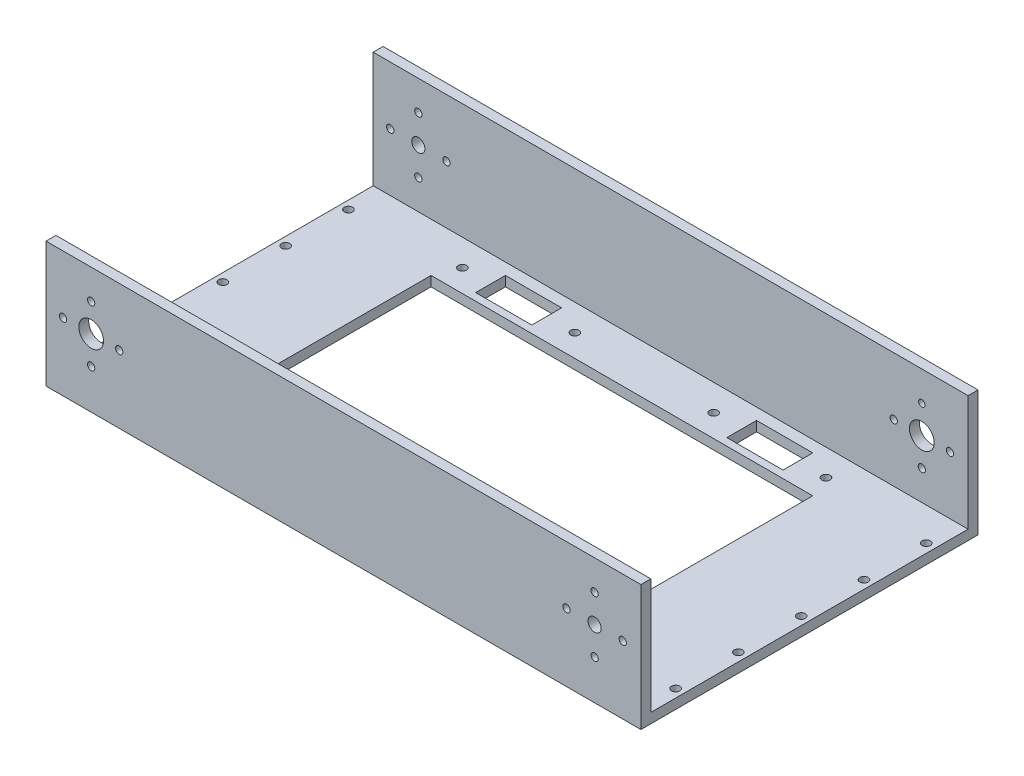
from build123d import *

# Parameters (mm, degrees)
SKETCH_1_W          = 180
SKETCH_1_H          = 35
EXTRUDE_1_DEPTH     = 3
SKETCH_2_R          = 3.75
SKETCH_2_R_2        = 2
CUT_EXTRUDE_1_DEPTH = 3
SKETCH_3_R          = 1.1
CUT_EXTRUDE_2_DEPTH = 3
SKETCH_4_W          = 180
SKETCH_4_H          = 102
EXTRUDE_2_DEPTH     = 3
SKETCH_5_W          = 180
SKETCH_5_H          = 3
EXTRUDE_3_DEPTH     = 35
SKETCH_6_R          = 3.75
SKETCH_6_R_2        = 2
SKETCH_6_R_3        = 1.1
SKETCH_6_R_4        = 0.981653735
CUT_EXTRUDE_3_DEPTH = 35
SKETCH_9_W          = 115.5
SKETCH_9_H          = 66.5
CUT_EXTRUDE_4_DEPTH = 10
SKETCH_10_R         = 1.25
CUT_EXTRUDE_5_DEPTH = 10
SKETCH_11_R         = 1.25
SKETCH_11_W         = 17
SKETCH_11_H         = 9
CUT_EXTRUDE_6_DEPTH = 10
SKETCH_12_R         = 1.25
CUT_EXTRUDE_7_DEPTH = 10


with BuildPart() as part:
    # 스케치1 → 보스-돌출1 (new body)
    with BuildSketch(Plane.XY):
        Rectangle(SKETCH_1_W, SKETCH_1_H)
    extrude(amount=EXTRUDE_1_DEPTH)

    # 스케치2 → 컷-돌출1 (cut)
    with BuildSketch(Plane.XY.offset(3)):
        with Locations((-76.33997629, 0)):
            Circle(SKETCH_2_R)
        with Locations((76, 0)):
            Circle(SKETCH_2_R_2)
    extrude(amount=-CUT_EXTRUDE_1_DEPTH, mode=Mode.SUBTRACT)

    # 스케치3 → 컷-돌출2 (cut)
    with BuildSketch(Plane.XY.offset(3)):
        with Locations((-76.33997629, 8.5)):
            Circle(SKETCH_3_R)
        with Locations((-76.33997629, -8.5)):
            Circle(SKETCH_3_R)
        with Locations((-84.83997629, 0)):
            Circle(SKETCH_3_R)
        with Locations((-67.83997629, 0)):
            Circle(SKETCH_3_R)
        with Locations((76, 8.5)):
            Circle(SKETCH_3_R)
        with Locations((76, -8.5)):
            Circle(SKETCH_3_R)
        with Locations((67.5, 0)):
            Circle(SKETCH_3_R)
        with Locations((84.5, 0)):
            Circle(SKETCH_3_R)
    extrude(amount=-CUT_EXTRUDE_2_DEPTH, mode=Mode.SUBTRACT)

    # 스케치4 → 보스-돌출2 (add)
    with BuildSketch(Plane.XZ.offset(17.5)):
        with Locations((0, -48)):
            Rectangle(SKETCH_4_W, SKETCH_4_H)
    extrude(amount=EXTRUDE_2_DEPTH)

    # 스케치5 → 보스-돌출3 (add)
    with BuildSketch(Plane(origin=(0, -17.5, 0), x_dir=(1, 0, 0), z_dir=(0, 1, 0))):
        with Locations((0, 97.5)):
            Rectangle(SKETCH_5_W, SKETCH_5_H)
    extrude(amount=EXTRUDE_3_DEPTH)

    # 스케치6 → 컷-돌출3 (cut)
    with BuildSketch(Plane(origin=(0, 0, -99), x_dir=(-1, 0, 0), z_dir=(0, 0, -1))):
        with Locations((-76, 0)):
            Circle(SKETCH_6_R)
        with Locations((76.33997629, 0)):
            Circle(SKETCH_6_R_2)
        with Locations((-76, -8.5)):
            Circle(SKETCH_6_R_3)
        with Locations((-67.5, 0)):
            Circle(SKETCH_6_R_3)
        with Locations((-76, 8.5)):
            Circle(SKETCH_6_R_4)
        with Locations((-84.5, 0)):
            Circle(SKETCH_6_R_3)
        with Locations((84.83997629, 0)):
            Circle(SKETCH_6_R_3)
        with Locations((76.33997629, 8.5)):
            Circle(SKETCH_6_R_3)
        with Locations((67.83997629, 0)):
            Circle(SKETCH_6_R_3)
        with Locations((76.33997629, -8.5)):
            Circle(SKETCH_6_R_3)
    extrude(amount=-CUT_EXTRUDE_3_DEPTH, mode=Mode.SUBTRACT)

    # 스케치9 → 컷-돌출4 (cut)
    with BuildSketch(Plane(origin=(0, -17.5, 0), x_dir=(1, 0, 0), z_dir=(0, 1, 0))):
        with Locations((0, 48)):
            Rectangle(SKETCH_9_W, SKETCH_9_H)
    extrude(amount=-CUT_EXTRUDE_4_DEPTH, mode=Mode.SUBTRACT)

    # 스케치10 → 컷-돌출5 (cut)
    with BuildSketch(Plane.XZ.offset(20.5)):
        with Locations((-55, -8)):
            Circle(SKETCH_10_R)
        with Locations((55, -8)):
            Circle(SKETCH_10_R)
        with Locations((55, -88)):
            Circle(SKETCH_10_R)
        with Locations((-55, -88)):
            Circle(SKETCH_10_R)
    extrude(amount=-CUT_EXTRUDE_5_DEPTH, mode=Mode.SUBTRACT)

    # 스케치11 → 컷-돌출6 (cut)
    with BuildSketch(Plane.XZ.offset(20.5)):
        with Locations((21, -8)):
            Circle(SKETCH_11_R)
        with Locations((-21, -8)):
            Circle(SKETCH_11_R)
        with Locations((21, -88)):
            Circle(SKETCH_11_R)
        with Locations((-21, -88)):
            Circle(SKETCH_11_R)
        with Locations((38, -88)):
            Rectangle(SKETCH_11_W, SKETCH_11_H)
        with Locations((-38, -88)):
            Rectangle(SKETCH_11_W, SKETCH_11_H)
        with Locations((38, -8)):
            Rectangle(SKETCH_11_W, SKETCH_11_H)
        with Locations((-38, -8)):
            Rectangle(SKETCH_11_W, SKETCH_11_H)
    extrude(amount=-CUT_EXTRUDE_6_DEPTH, mode=Mode.SUBTRACT)

    # 스케치12 → 컷-돌출7 (cut)
    with BuildSketch(Plane(origin=(0, -17.5, 0), x_dir=(1, 0, 0), z_dir=(0, 1, 0))):
        with Locations((-87.5, 86)):
            Circle(SKETCH_12_R)
        with Locations((-87.5, 67)):
            Circle(SKETCH_12_R)
        with Locations((-87.5, 48)):
            Circle(SKETCH_12_R)
        with Locations((-87.5, 29)):
            Circle(SKETCH_12_R)
        with Locations((-87.5, 10)):
            Circle(SKETCH_12_R)
        with Locations((87.328433312, 86)):
            Circle(SKETCH_12_R)
        with Locations((87.5, 67)):
            Circle(SKETCH_12_R)
        with Locations((87.5, 48)):
            Circle(SKETCH_12_R)
        with Locations((87.5, 29)):
            Circle(SKETCH_12_R)
        with Locations((87.5, 10)):
            Circle(SKETCH_12_R)
    extrude(amount=-CUT_EXTRUDE_7_DEPTH, mode=Mode.SUBTRACT)


solid = part.part
